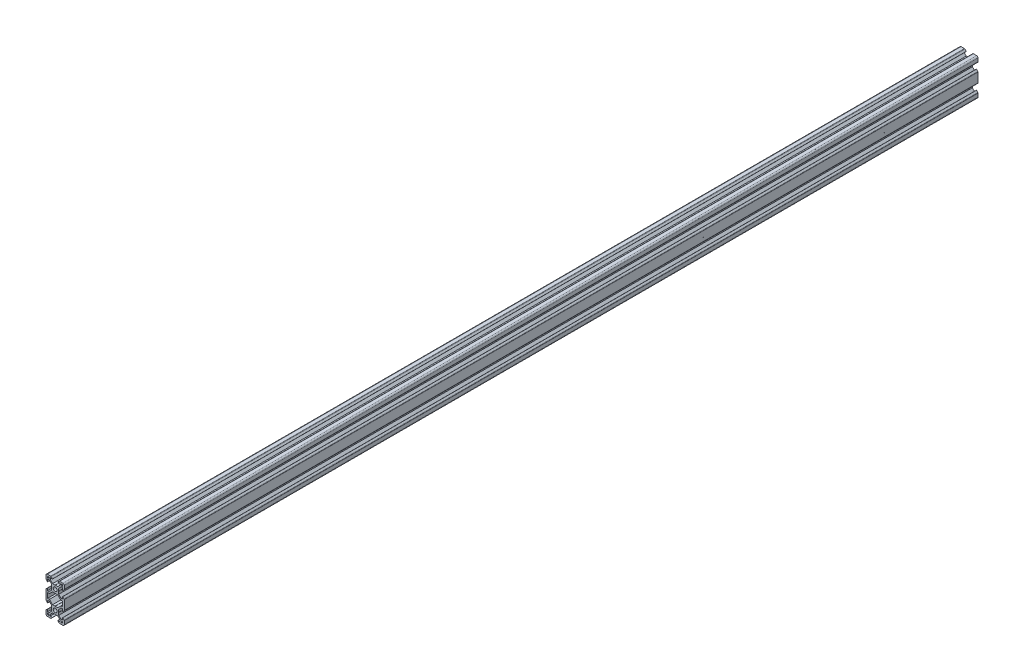
from build123d import *

# Parameters (mm, degrees)
SKETCH2_R           = 2.1
BOSS_EXTRUDE1_DEPTH = 1000


with BuildPart() as part:
    # Sketch2 → Boss-Extrude1 (new body)
    with BuildSketch(Plane.XY):
        with BuildLine():
            Line((-0.1, 3.9), (0, 3.8))
            Line((0, 3.8), (0.1, 3.9))
            Line((0.1, 3.9), (2.840365134, 3.9))
            Line((2.840365134, 3.9), (5.5, 6.558825842))
            Line((5.5, 6.558825842), (5.5, 8.197505675))
            Line((5.5, 8.197505675), (2.89, 8.197505675))
            Line((2.89, 8.197505675), (2.89, 8.307505675))
            Line((2.89, 8.307505675), (4.348614357, 9.766120032))
            ThreePointArc((4.348614357, 9.766120032), (4.604908803, 9.937370505), (4.907228714, 9.997505675))
            Line((4.907228714, 9.997505675), (8.5, 9.997505675))
            ThreePointArc((8.5, 9.997505675), (9.560660172, 9.558165846), (10, 8.497505675))
            Line((10, 8.497505675), (10, 4.904734389))
            ThreePointArc((10, 4.904734389), (9.939864831, 4.602414477), (9.768614357, 4.346120032))
            Line((9.768614357, 4.346120032), (8.31, 2.887505675))
            Line((8.31, 2.887505675), (8.2, 2.887505675))
            Line((8.2, 2.887505675), (8.2, 5.497505675))
            Line((8.2, 5.497505675), (6.56, 5.497505675))
            Line((6.56, 5.497505675), (3.9, 2.83831481))
            Line((3.9, 2.83831481), (3.9, 0.1))
            Line((3.9, 0.1), (3.8, 0))
            Line((3.8, 0), (3.9, -0.1))
            Line((3.9, -0.1), (3.9, -2.84))
            Line((3.9, -2.84), (6.56, -5.5))
            Line((6.56, -5.5), (8.2, -5.5))
            Line((8.2, -5.5), (8.2, -2.89))
            Line((8.2, -2.89), (8.31, -2.89))
            Line((8.31, -2.89), (9.765685425, -4.345685425))
            ThreePointArc((9.765685425, -4.345685425), (9.939103626, -4.605224104), (10, -4.91137085))
            Line((10, -4.91137085), (10, -15.08862915))
            ThreePointArc((10, -15.08862915), (9.939103626, -15.394775896), (9.765685425, -15.654314575))
            Line((9.765685425, -15.654314575), (8.31, -17.11))
            Line((8.31, -17.11), (8.2, -17.11))
            Line((8.2, -17.11), (8.2, -14.5))
            Line((8.2, -14.5), (6.56, -14.5))
            Line((6.56, -14.5), (3.9, -17.16))
            Line((3.9, -17.16), (3.9, -19.9))
            Line((3.9, -19.9), (3.8, -20))
            Line((3.8, -20), (3.9, -20.1))
            Line((3.9, -20.1), (3.9, -22.83831481))
            Line((3.9, -22.83831481), (6.56, -25.497505675))
            Line((6.56, -25.497505675), (8.2, -25.497505675))
            Line((8.2, -25.497505675), (8.2, -22.887505675))
            Line((8.2, -22.887505675), (8.31, -22.887505675))
            Line((8.31, -22.887505675), (9.768614357, -24.346120032))
            ThreePointArc((9.768614357, -24.346120032), (9.939864831, -24.602414477), (10, -24.904734389))
            Line((10, -24.904734389), (10, -28.497505675))
            ThreePointArc((10, -28.497505675), (9.560660172, -29.558165846), (8.5, -29.997505675))
            Line((8.5, -29.997505675), (4.907228714, -29.997505675))
            ThreePointArc((4.907228714, -29.997505675), (4.604908803, -29.937370505), (4.348614357, -29.766120032))
            Line((4.348614357, -29.766120032), (2.89, -28.307505675))
            Line((2.89, -28.307505675), (2.89, -28.197505675))
            Line((2.89, -28.197505675), (5.5, -28.197505675))
            Line((5.5, -28.197505675), (5.5, -26.558825842))
            Line((5.5, -26.558825842), (2.840365134, -23.9))
            Line((2.840365134, -23.9), (0.1, -23.9))
            Line((0.1, -23.9), (0, -23.8))
            Line((0, -23.8), (-0.1, -23.9))
            Line((-0.1, -23.9), (-2.840365134, -23.9))
            Line((-2.840365134, -23.9), (-5.5, -26.558825842))
            Line((-5.5, -26.558825842), (-5.5, -28.197505675))
            Line((-5.5, -28.197505675), (-2.89, -28.197505675))
            Line((-2.89, -28.197505675), (-2.89, -28.307505675))
            Line((-2.89, -28.307505675), (-4.348614357, -29.766120032))
            ThreePointArc((-4.348614357, -29.766120032), (-4.604908803, -29.937370505), (-4.907228714, -29.997505675))
            Line((-4.907228714, -29.997505675), (-8.5, -29.997505675))
            ThreePointArc((-8.5, -29.997505675), (-9.560660172, -29.558165846), (-10, -28.497505675))
            Line((-10, -28.497505675), (-10, -24.904734389))
            ThreePointArc((-10, -24.904734389), (-9.939864831, -24.602414477), (-9.768614357, -24.346120032))
            Line((-9.768614357, -24.346120032), (-8.31, -22.887505675))
            Line((-8.31, -22.887505675), (-8.2, -22.887505675))
            Line((-8.2, -22.887505675), (-8.2, -25.497505675))
            Line((-8.2, -25.497505675), (-6.56, -25.497505675))
            Line((-6.56, -25.497505675), (-3.9, -22.83831481))
            Line((-3.9, -22.83831481), (-3.9, -20.1))
            Line((-3.9, -20.1), (-3.8, -20))
            Line((-3.8, -20), (-3.9, -19.9))
            Line((-3.9, -19.9), (-3.9, -17.16))
            Line((-3.9, -17.16), (-6.56, -14.5))
            Line((-6.56, -14.5), (-8.2, -14.5))
            Line((-8.2, -14.5), (-8.2, -17.11))
            Line((-8.2, -17.11), (-8.31, -17.11))
            Line((-8.31, -17.11), (-9.765685425, -15.654314575))
            ThreePointArc((-9.765685425, -15.654314575), (-9.939103626, -15.394775896), (-10, -15.08862915))
            Line((-10, -15.08862915), (-10, -4.91137085))
            ThreePointArc((-10, -4.91137085), (-9.939103626, -4.605224104), (-9.765685425, -4.345685425))
            Line((-9.765685425, -4.345685425), (-8.31, -2.89))
            Line((-8.31, -2.89), (-8.2, -2.89))
            Line((-8.2, -2.89), (-8.2, -5.5))
            Line((-8.2, -5.5), (-6.56, -5.5))
            Line((-6.56, -5.5), (-3.9, -2.84))
            Line((-3.9, -2.84), (-3.9, -0.1))
            Line((-3.9, -0.1), (-3.8, 0))
            Line((-3.8, 0), (-3.9, 0.1))
            Line((-3.9, 0.1), (-3.9, 2.83831481))
            Line((-3.9, 2.83831481), (-6.56, 5.497505675))
            Line((-6.56, 5.497505675), (-8.2, 5.497505675))
            Line((-8.2, 5.497505675), (-8.2, 2.887505675))
            Line((-8.2, 2.887505675), (-8.31, 2.887505675))
            Line((-8.31, 2.887505675), (-9.768614357, 4.346120032))
            ThreePointArc((-9.768614357, 4.346120032), (-9.939864831, 4.602414477), (-10, 4.904734389))
            Line((-10, 4.904734389), (-10, 8.497505675))
            ThreePointArc((-10, 8.497505675), (-9.560660172, 9.558165846), (-8.5, 9.997505675))
            Line((-8.5, 9.997505675), (-4.907228714, 9.997505675))
            ThreePointArc((-4.907228714, 9.997505675), (-4.604908803, 9.937370505), (-4.348614357, 9.766120032))
            Line((-4.348614357, 9.766120032), (-2.89, 8.307505675))
            Line((-2.89, 8.307505675), (-2.89, 8.197505675))
            Line((-2.89, 8.197505675), (-5.5, 8.197505675))
            Line((-5.5, 8.197505675), (-5.5, 6.558825842))
            Line((-5.5, 6.558825842), (-2.840365134, 3.9))
            Line((-2.840365134, 3.9), (-0.1, 3.9))
        make_face()
        Circle(SKETCH2_R, mode=Mode.SUBTRACT)
        with Locations((0, -20)):
            Circle(SKETCH2_R, mode=Mode.SUBTRACT)
        Polygon((-7.66, 6.567505675), (-6.57, 7.657505675), (-6.57, 8.197505675), (-8.2, 8.197505675), (-8.2, 6.567505675), align=None, mode=Mode.SUBTRACT)
        Polygon((-0.1, -3.9), (0, -3.8), (0.1, -3.9), (2.840365134, -3.9), (6.24, -7.299634866), (8.2, -7.299634866), (8.2, -12.700365134), (6.24, -12.700365134), (2.840365134, -16.1), (0.1, -16.1), (0, -16.2), (-0.1, -16.1), (-2.840365134, -16.1), (-6.24, -12.700365134), (-8.2, -12.700365134), (-8.2, -7.299634866), (-6.24, -7.299634866), (-2.840365134, -3.9), align=None, mode=Mode.SUBTRACT)
        Polygon((8.2, 6.567505675), (7.66, 6.567505675), (6.57, 7.657505675), (6.57, 8.197505675), (8.2, 8.197505675), align=None, mode=Mode.SUBTRACT)
        Polygon((7.66, -26.567505675), (6.57, -27.657505675), (6.57, -28.197505675), (8.2, -28.197505675), (8.2, -26.567505675), align=None, mode=Mode.SUBTRACT)
        Polygon((-8.2, -26.567505675), (-7.66, -26.567505675), (-6.57, -27.657505675), (-6.57, -28.197505675), (-8.2, -28.197505675), align=None, mode=Mode.SUBTRACT)
    extrude(amount=-BOSS_EXTRUDE1_DEPTH)


solid = part.part
